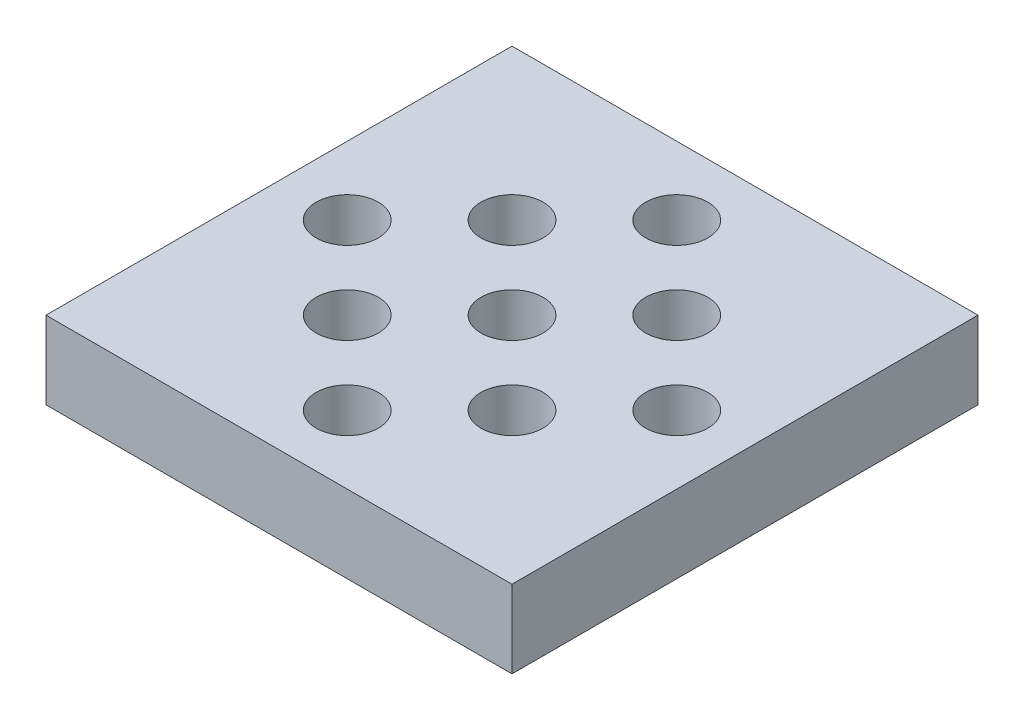
from build123d import *

# Parameters (mm, degrees)
SKETCH1_W            = 60
SKETCH1_H            = 60
BOSS_EXTRUDE1_DEPTH  = 10
CUT_EXTRUDE1_DEPTH   = 10
LPATTERN1_COUNT      = 3
LPATTERN1_PITCH      = 15
LPATTERN1_COUNT_DIR2 = 3
LPATTERN1_PITCH_DIR2 = 15


with BuildPart() as part:
    # Sketch1 → Boss-Extrude1 (new body)
    with BuildSketch(Plane(origin=(0, 0, 0), x_dir=(1, 0, 0), z_dir=(0, 1, 0))):
        Rectangle(SKETCH1_W, SKETCH1_H)
    extrude(amount=BOSS_EXTRUDE1_DEPTH)

    # Sketch2 → Cut-Extrude1 (cut)
    with BuildSketch(Plane.XZ):
        with BuildLine():
            ThreePointArc((-3.578736933, -23), (0, -25.213203436), (3.578736933, -23))
            Line((3.578736933, -23), (-3.578736933, -23))
        make_face()
        with BuildLine():
            Line((-3.578736933, -23), (3.578736933, -23))
            ThreePointArc((3.578736933, -23), (3.893260056, -22.131095659), (4, -21.213203436))
            ThreePointArc((4, -21.213203436), (-0.917892223, -17.319943379), (-3.578736933, -23))
        make_face()
    cut_extrude1 = extrude(amount=-CUT_EXTRUDE1_DEPTH, mode=Mode.SUBTRACT)

    # LPattern1: Cut-Extrude1 3 × 3
    with Locations(*[Vector(-0.707106781, 0, 0.707106781) * (i * LPATTERN1_PITCH) + Vector(0.707106781, 0, 0.707106781) * (j * LPATTERN1_PITCH_DIR2) for i in range(LPATTERN1_COUNT) for j in range(LPATTERN1_COUNT_DIR2) if (i, j) != (0, 0)]):
        add(cut_extrude1, mode=Mode.SUBTRACT)


solid = part.part
